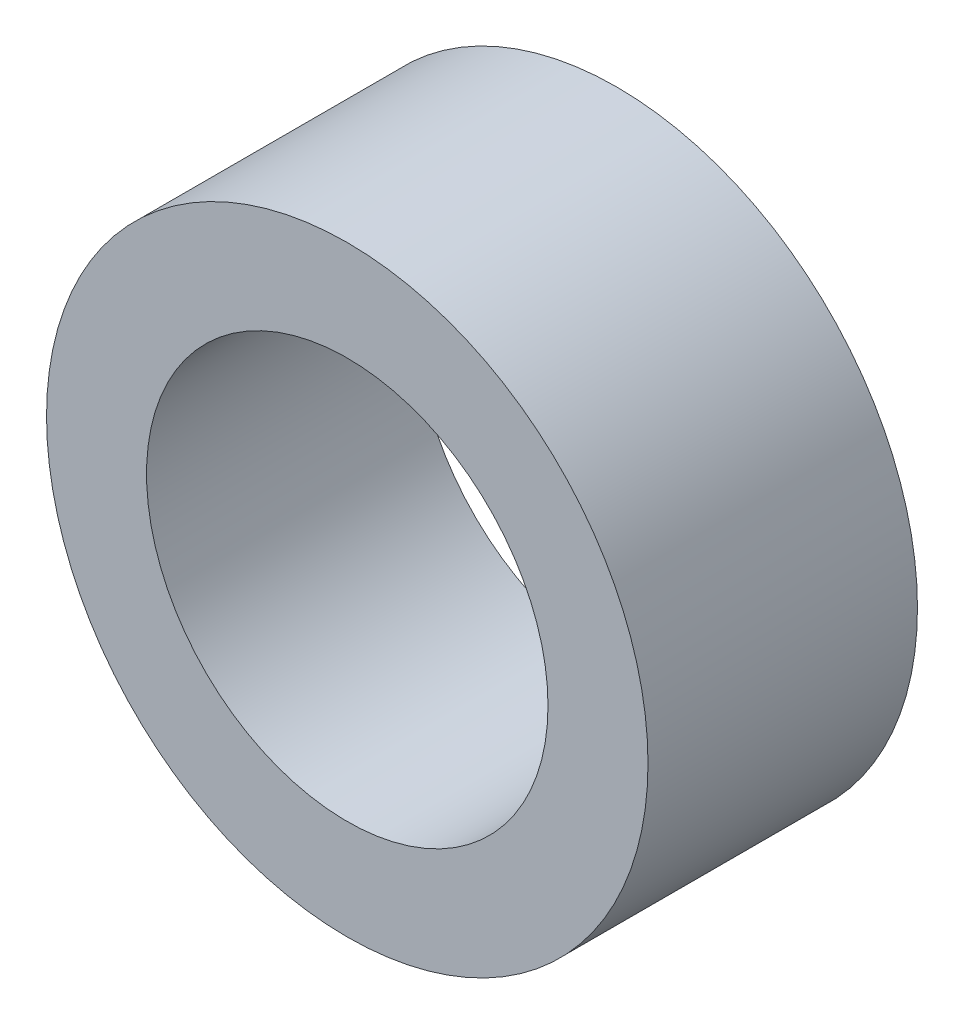
from build123d import *

# Parameters (mm, degrees)
SKETCH3_R                = 4.7625
SKETCH3_R_2              = 3.17881
BOSS_EXTRUDE1_DEPTH      = 2.1336
BOSS_EXTRUDE1_DEPTH_BACK = 2.1336


with BuildPart() as part:
    # Sketch3 → Boss-Extrude1 (new body, two sides)
    with BuildSketch(Plane.XY) as boss_extrude1_sk:
        Circle(SKETCH3_R)
        Circle(SKETCH3_R_2, mode=Mode.SUBTRACT)
    extrude(amount=BOSS_EXTRUDE1_DEPTH)
    extrude(boss_extrude1_sk.sketch, amount=-BOSS_EXTRUDE1_DEPTH_BACK)


solid = part.part
